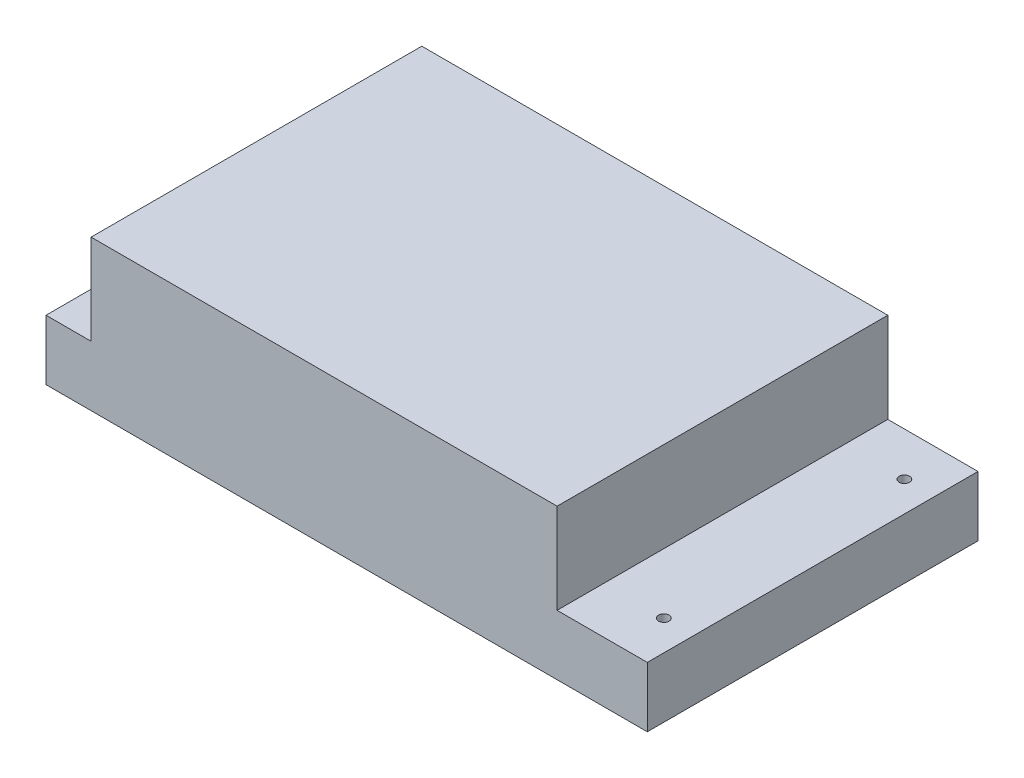
from build123d import *

# Parameters (mm, degrees)
SKETCH1_W           = 200
SKETCH1_H           = 110
BOSS_EXTRUDE1_DEPTH = 50
SKETCH2_W           = 30
SKETCH2_H           = 110
SKETCH2_W_2         = 15
CUT_EXTRUDE1_DEPTH  = 30
SKETCH3_R           = 1.75
CUT_EXTRUDE2_DEPTH  = 30


with BuildPart() as part:
    # Sketch1 → Boss-Extrude1 (new body)
    with BuildSketch(Plane(origin=(0, 0, 0), x_dir=(1, 0, 0), z_dir=(0, 1, 0))):
        with Locations((100, 55)):
            Rectangle(SKETCH1_W, SKETCH1_H)
    extrude(amount=BOSS_EXTRUDE1_DEPTH)

    # Sketch2 → Cut-Extrude1 (cut)
    with BuildSketch(Plane(origin=(0, 50, 0), x_dir=(1, 0, 0), z_dir=(0, 1, 0))):
        with Locations((185, 55)):
            Rectangle(SKETCH2_W, SKETCH2_H)
        with Locations((7.5, 55)):
            Rectangle(SKETCH2_W_2, SKETCH2_H)
    extrude(amount=-CUT_EXTRUDE1_DEPTH, mode=Mode.SUBTRACT)

    # Sketch3 → Cut-Extrude2 (cut)
    with BuildSketch(Plane(origin=(0, 20, 0), x_dir=(1, 0, 0), z_dir=(0, 1, 0))):
        with Locations((190, 95.5)):
            Circle(SKETCH3_R)
        with Locations((190, 15.5)):
            Circle(SKETCH3_R)
        with Locations((10, 95.5)):
            Circle(SKETCH3_R)
        with Locations((10, 15.5)):
            Circle(SKETCH3_R)
    extrude(amount=-CUT_EXTRUDE2_DEPTH, mode=Mode.SUBTRACT)


solid = part.part
